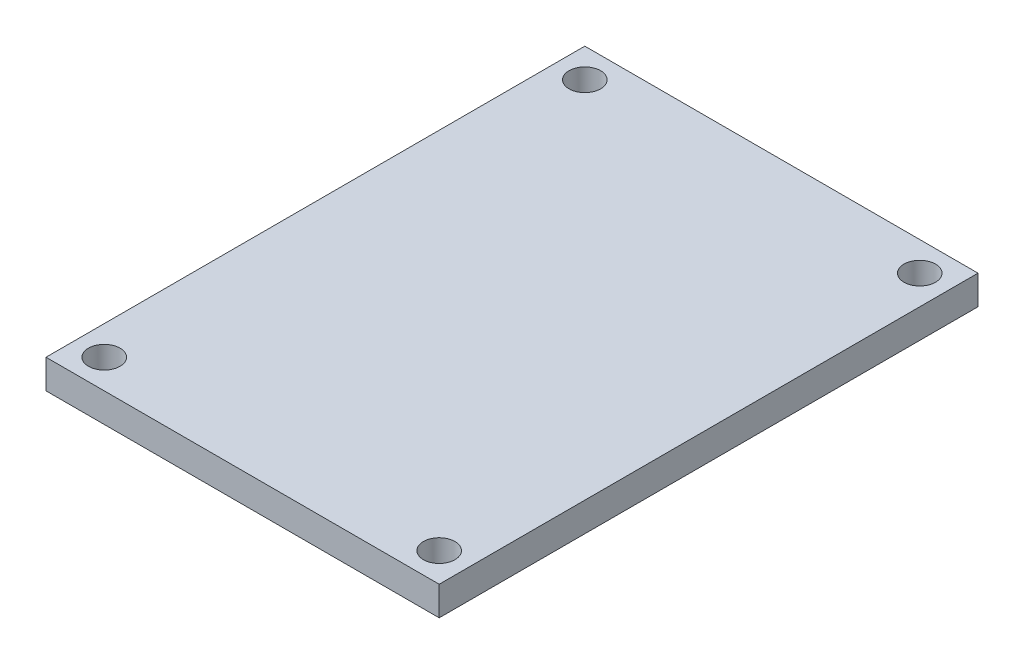
from build123d import *

# Parameters (mm, degrees)
SKETCH1_W               = 40.5
SKETCH1_H               = 55.5
BOSS_EXTRUDE1_DEPTH     = 3
SKETCH2_R               = 1.625
CUT_EXTRUDE1_DEPTH      = 1
CUT_EXTRUDE1_DEPTH_BACK = 4


with BuildPart() as part:
    # Sketch1 → Boss-Extrude1 (new body)
    with BuildSketch(Plane(origin=(0, 0, 0), x_dir=(1, 0, 0), z_dir=(0, 1, 0))):
        Rectangle(SKETCH1_W, SKETCH1_H)
    extrude(amount=BOSS_EXTRUDE1_DEPTH)

    # Sketch2 → Cut-Extrude1 (cut, two sides)
    with BuildSketch(Plane(origin=(0, 3, 0), x_dir=(1, 0, 0), z_dir=(0, 1, 0))) as cut_extrude1_sk:
        with Locations((-17.25, 24.75)):
            Circle(SKETCH2_R)
        with Locations((17.25, 24.75)):
            Circle(SKETCH2_R)
        with Locations((17.25, -24.75)):
            Circle(SKETCH2_R)
        with Locations((-17.25, -24.75)):
            Circle(SKETCH2_R)
    extrude(amount=CUT_EXTRUDE1_DEPTH, mode=Mode.SUBTRACT)
    extrude(cut_extrude1_sk.sketch, amount=-CUT_EXTRUDE1_DEPTH_BACK, mode=Mode.SUBTRACT)


solid = part.part
